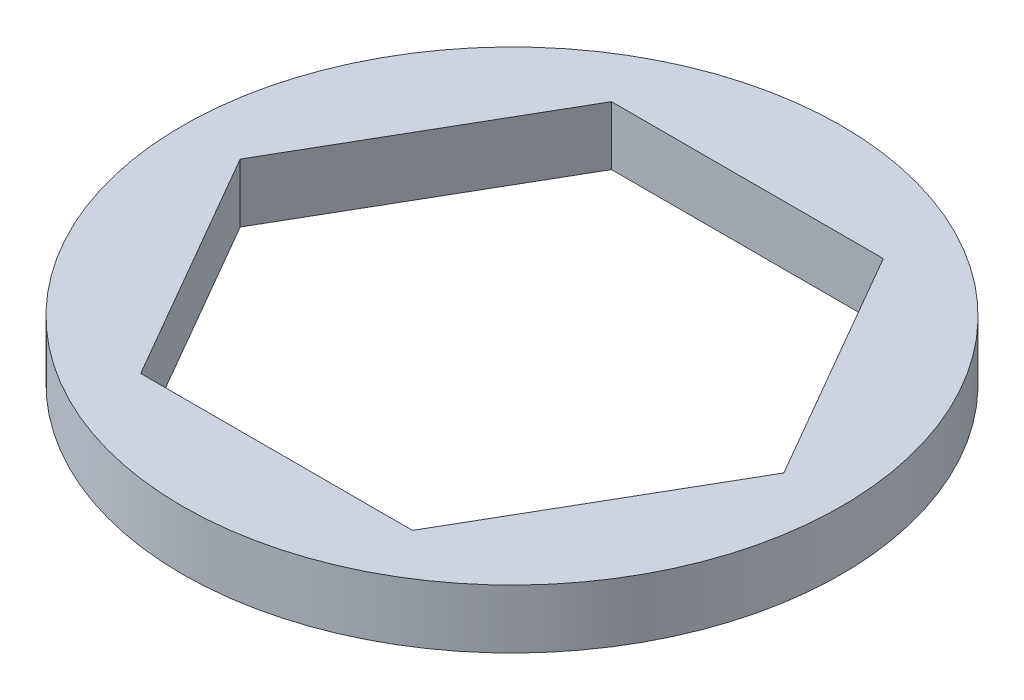
from build123d import *

# Parameters (mm, degrees)
SKETCH1_R           = 8.89
BOSS_EXTRUDE1_DEPTH = 1.5875


with BuildPart() as part:
    # Sketch1 → Boss-Extrude1 (new body)
    with BuildSketch(Plane(origin=(0, 0, 0), x_dir=(1, 0, 0), z_dir=(0, 1, 0))):
        Circle(SKETCH1_R)
        Polygon((7.332348419, 0), (3.666174209, 6.35), (-3.666174209, 6.35), (-7.332348419, 0), (-3.666174209, -6.35), (3.666174209, -6.35), align=None, mode=Mode.SUBTRACT)
    extrude(amount=BOSS_EXTRUDE1_DEPTH)


solid = part.part
